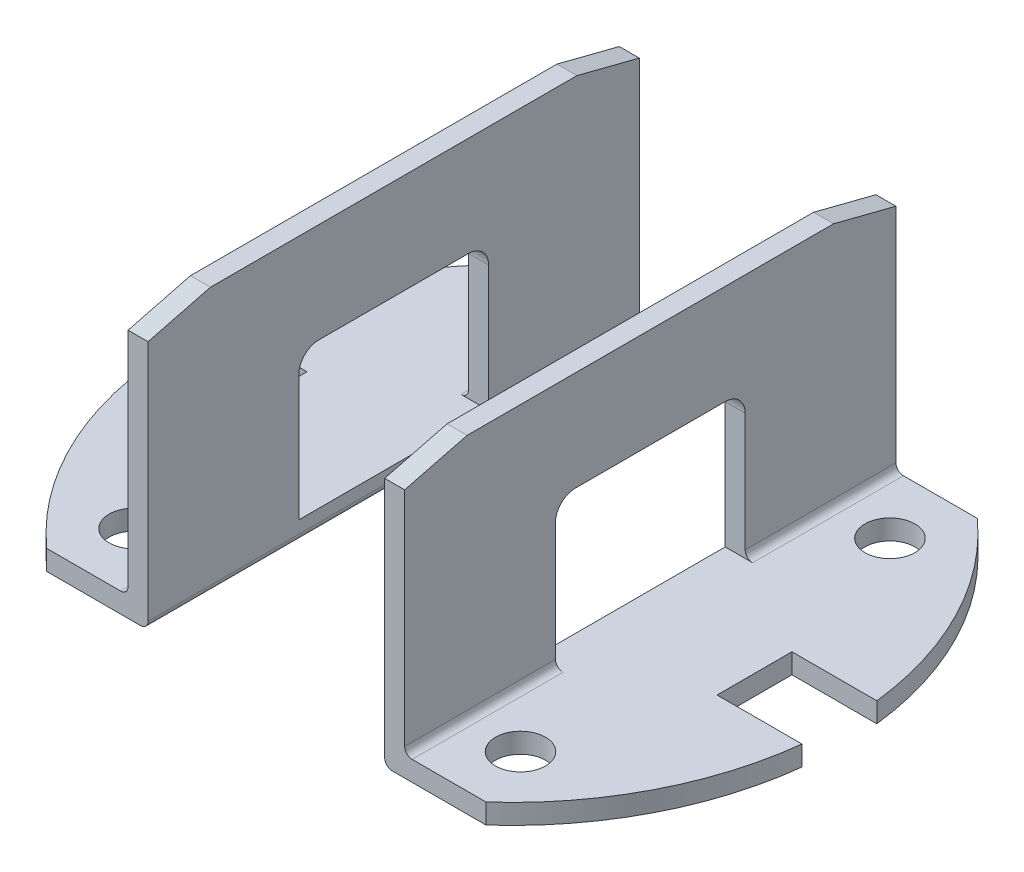
from build123d import *

# Parameters (mm, degrees)
SKETCH1_R               = 1.27
BOSS_EXTRUDE1_DEPTH     = 1.016
BOSS_EXTRUDE1_2_DEPTH   = 1.016
SKETCH2_W               = 1.016
SKETCH2_H               = 24.9936
BOSS_EXTRUDE2_DEPTH     = 13.5128
CUT_EXTRUDE1_DEPTH      = 13.5128
CUT_EXTRUDE1_DEPTH_BACK = 13.5128
FILLET1_R               = 0.381
FILLET2_R               = 0.381


with BuildPart() as part:
    # Sketch1 → Boss-Extrude1 (new body)
    with BuildSketch(Plane(origin=(0, 0, 0), x_dir=(1, 0, 0), z_dir=(0, 1, 0))):
        with BuildLine():
            Line((11.174152575, 12.4968), (6.0198, 12.4968))
            Line((6.0198, 12.4968), (6.0198, -12.4968))
            Line((6.0198, -12.4968), (11.174152575, -12.4968))
            ThreePointArc((11.174152575, -12.4968), (14.888508669, -7.704804061), (16.655409662, -1.905))
            Line((16.655409662, -1.905), (12.337409662, -1.905))
            Line((12.337409662, -1.905), (12.337409662, 1.905))
            Line((12.337409662, 1.905), (16.655409662, 1.905))
            ThreePointArc((16.655409662, 1.905), (14.888508669, 7.704804061), (11.174152575, 12.4968))
        make_face()
        with Locations((9.8298, -9.398)):
            Circle(SKETCH1_R, mode=Mode.SUBTRACT)
        with Locations((9.8298, 9.398)):
            Circle(SKETCH1_R, mode=Mode.SUBTRACT)
    extrude(amount=BOSS_EXTRUDE1_DEPTH)



with BuildPart() as body_2:
    # Sketch1 → Boss-Extrude1 2 (new body)
    with BuildSketch(Plane(origin=(0, 0, 0), x_dir=(1, 0, 0), z_dir=(0, 1, 0))):
        with BuildLine():
            Line((-6.0198, -12.4968), (-11.174152575, -12.4968))
            ThreePointArc((-11.174152575, -12.4968), (-14.888508669, -7.704804061), (-16.655409662, -1.905))
            Line((-16.655409662, -1.905), (-12.337409662, -1.905))
            Line((-12.337409662, -1.905), (-12.337409662, 1.905))
            Line((-12.337409662, 1.905), (-16.655409662, 1.905))
            ThreePointArc((-16.655409662, 1.905), (-14.888508669, 7.704804061), (-11.174152575, 12.4968))
            Line((-11.174152575, 12.4968), (-6.0198, 12.4968))
            Line((-6.0198, 12.4968), (-6.0198, -12.4968))
        make_face()
        with Locations((-9.8298, 9.398)):
            Circle(SKETCH1_R, mode=Mode.SUBTRACT)
        with Locations((-9.8298, -9.398)):
            Circle(SKETCH1_R, mode=Mode.SUBTRACT)
    extrude(amount=BOSS_EXTRUDE1_2_DEPTH)


with BuildPart() as part_1:
    add(part.part)

    add(body_2.part)  # Boss-Extrude2 merges body 2
    # Sketch2 → Boss-Extrude2 (add)
    with BuildSketch(Plane(origin=(0, 0, 0), x_dir=(1, 0, 0), z_dir=(0, 1, 0))):
        with Locations((-6.5278, 0)):
            Rectangle(SKETCH2_W, SKETCH2_H)
        with Locations((6.5278, 0)):
            Rectangle(SKETCH2_W, SKETCH2_H)
    extrude(amount=BOSS_EXTRUDE2_DEPTH)

    # Sketch3 → Cut-Extrude1 (cut, two sides)
    with BuildSketch(Plane(origin=(0, 0, 0), x_dir=(0, 0, -1), z_dir=(1, 0, 0))) as cut_extrude1_sk:
        Polygon((-12.4968, 13.5128), (-9.3218, 13.5128), (-12.4968, 12.7), align=None)
        Polygon((12.4968, 13.5128), (12.4968, 12.7), (9.3218, 13.5128), align=None)
        with BuildLine():
            Line((-4.826, 7.4168), (-4.826, 1.016))
            Line((-4.826, 1.016), (4.826, 1.016))
            Line((4.826, 1.016), (4.826, 7.4168))
            ThreePointArc((4.826, 7.4168), (4.52842049, 8.13522049), (3.81, 8.4328))
            Line((3.81, 8.4328), (-3.81, 8.4328))
            ThreePointArc((-3.81, 8.4328), (-4.52842049, 8.13522049), (-4.826, 7.4168))
        make_face()
    extrude(amount=CUT_EXTRUDE1_DEPTH, mode=Mode.SUBTRACT)
    extrude(cut_extrude1_sk.sketch, amount=-CUT_EXTRUDE1_DEPTH_BACK, mode=Mode.SUBTRACT)

    # Fillet1
    fillet1_edges = [part_1.edges().sort_by_distance(p)[0] for p in [
        (-7.0358, 1.016, 8.6614),
        (-7.0358, 1.016, -8.6614),
        (-6.0198, 0, 0),
    ]]
    fillet(fillet1_edges, radius=FILLET1_R)

    # Fillet2
    fillet2_edges = [part_1.edges().sort_by_distance(p)[0] for p in [
        (7.0358, 1.016, -8.6614),
        (7.0358, 1.016, 8.6614),
        (6.0198, 0, 0),
    ]]
    fillet(fillet2_edges, radius=FILLET2_R)


solid = part_1.part
